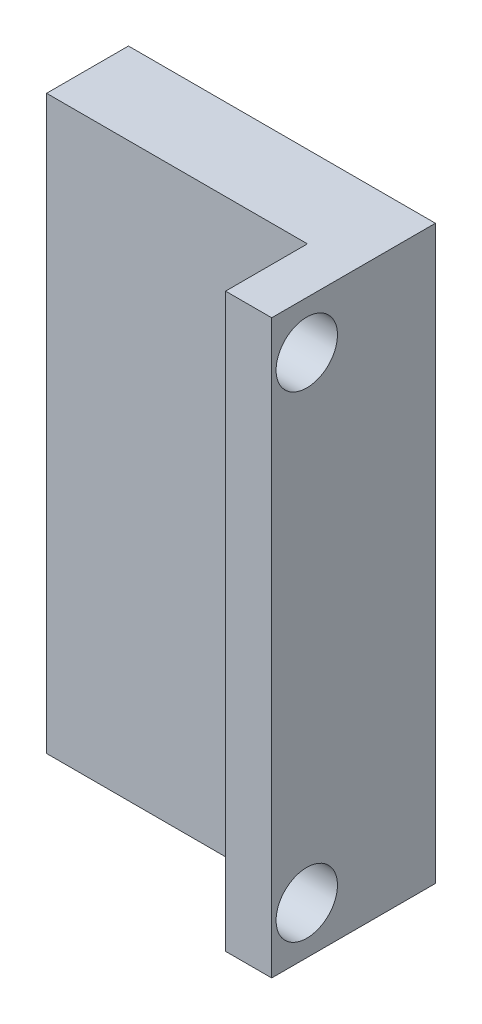
from build123d import *

# Parameters (mm, degrees)
SKETCH2_W           = 10
SKETCH2_H           = 10
BOSS_EXTRUDE1_DEPTH = 5
SKETCH4_W           = 15
SKETCH4_H           = 27.94
BOSS_EXTRUDE4_DEPTH = 4
SKETCH5_W           = 2.25448465
SKETCH5_H           = 27.94
BOSS_EXTRUDE5_DEPTH = 4
SKETCH6_R           = 1.5
CUT_EXTRUDE1_DEPTH  = 40
SKETCH7_R           = 3.5
BOSS_EXTRUDE6_DEPTH = 8
SKETCH8_W           = 10
SKETCH8_H           = 10
CUT_EXTRUDE2_DEPTH  = 13


with BuildPart() as part:
    # Sketch2 → Boss-Extrude1 (new body)
    with BuildSketch(Plane.XY):
        with Locations((5, 5)):
            Rectangle(SKETCH2_W, SKETCH2_H)
    extrude(amount=BOSS_EXTRUDE1_DEPTH)

    # Sketch4 → Boss-Extrude4 (add)
    with BuildSketch(Plane.XY.offset(5)):
        with Locations((7.5, 5)):
            Rectangle(SKETCH4_W, SKETCH4_H)
    extrude(amount=BOSS_EXTRUDE4_DEPTH)

    # Sketch5 → Boss-Extrude5 (add)
    with BuildSketch(Plane.XY.offset(9)):
        with Locations((13.872757675, 5)):
            Rectangle(SKETCH5_W, SKETCH5_H)
    extrude(amount=BOSS_EXTRUDE5_DEPTH)

    # Sketch6 → Cut-Extrude1 (cut)
    with BuildSketch(Plane.ZY.offset(-12.74551535)):
        with Locations((11.286, 16.64426)):
            Circle(SKETCH6_R)
        with Locations((11.286, -6.645)):
            Circle(SKETCH6_R)
    extrude(amount=-CUT_EXTRUDE1_DEPTH, mode=Mode.SUBTRACT)

    # Sketch7 → Boss-Extrude6 (add)
    with BuildSketch(Plane(origin=(0, 0, 0), x_dir=(-1, 0, 0), z_dir=(0, 0, -1))):
        with Locations((-5, 5)):
            Circle(SKETCH7_R)
    extrude(amount=BOSS_EXTRUDE6_DEPTH)

    # Sketch8 → Cut-Extrude2 (cut)
    with BuildSketch(Plane(origin=(0, 0, -8), x_dir=(-1, 0, 0), z_dir=(0, 0, -1))):
        with Locations((-5, 5)):
            Rectangle(SKETCH8_W, SKETCH8_H)
    extrude(amount=-CUT_EXTRUDE2_DEPTH, mode=Mode.SUBTRACT)


solid = part.part
